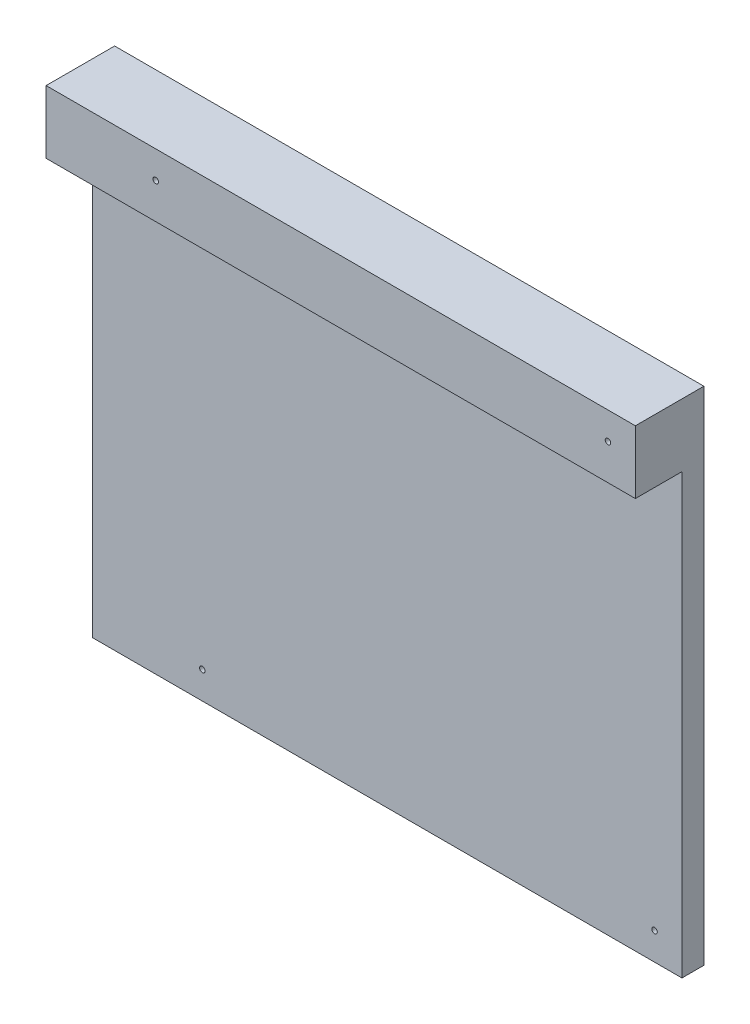
from build123d import *

# Parameters (mm, degrees)
CROQUIS1_W              = 215
CROQUIS1_H              = 160
CROQUIS1_R              = 1
SALIENTE_EXTRUIR1_DEPTH = 8
CROQUIS1_3_W            = 215
CROQUIS1_3_H            = 23
CROQUIS1_3_R            = 1
SALIENTE_EXTRUIR2_DEPTH = 25


with BuildPart() as part:
    # Croquis1 → Saliente-Extruir1 (new body)
    with BuildSketch(Plane.XY):
        with Locations((73.249006664, -76.149492386)):
            Rectangle(CROQUIS1_W, CROQUIS1_H)
        with Locations((5.749006664, -146.149492386)):
            Circle(CROQUIS1_R, mode=Mode.SUBTRACT)
        with Locations((170.749006664, -146.149492386)):
            Circle(CROQUIS1_R, mode=Mode.SUBTRACT)
    extrude(amount=SALIENTE_EXTRUIR1_DEPTH)

    # Croquis1_3 → Saliente-Extruir2 (add)
    with BuildSketch(Plane.XY):
        with Locations((73.249006664, 15.350507614)):
            Rectangle(CROQUIS1_3_W, CROQUIS1_3_H)
        with Locations((5.749006664, 16.850507614)):
            Circle(CROQUIS1_3_R, mode=Mode.SUBTRACT)
        with Locations((170.749006664, 16.850507614)):
            Circle(CROQUIS1_3_R, mode=Mode.SUBTRACT)
    extrude(amount=SALIENTE_EXTRUIR2_DEPTH)


solid = part.part
